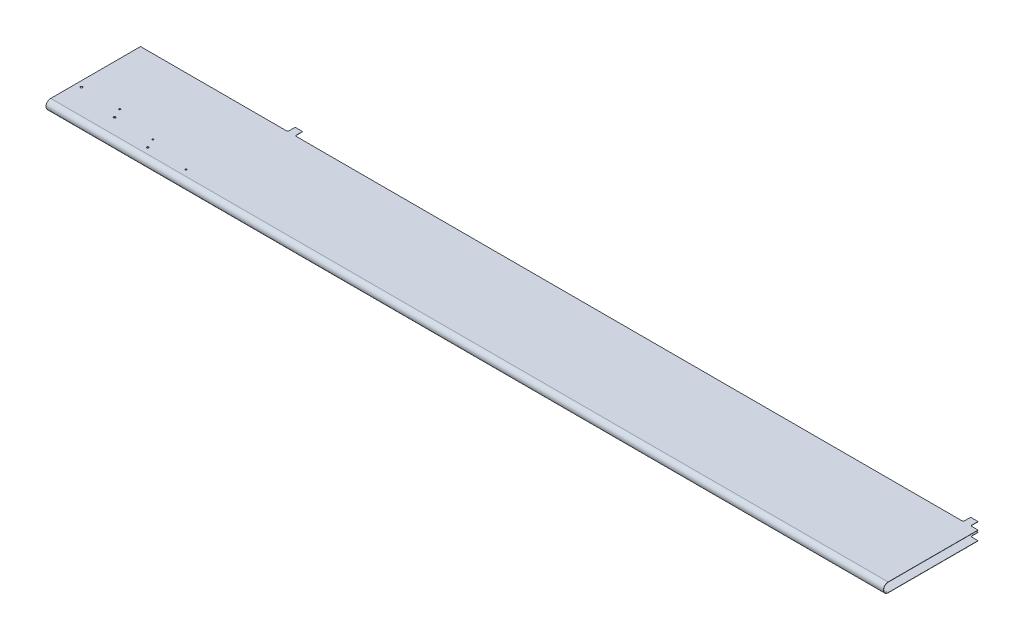
from build123d import *

# Parameters (mm, degrees)
BOSS_EXTRUDE1_DEPTH      = 5
BOSS_EXTRUDE1_DEPTH_BACK = 563.8
CUT_EXTRUDE1_DEPTH       = 7.42512
BOSS_EXTRUDE2_DEPTH      = 91.3
SKETCH4_R                = 0.69
SKETCH4_R_2              = 0.51
CUT_EXTRUDE2_DEPTH       = 2


with BuildPart() as part:
    # Sketch1 → Boss-Extrude1 (new body, two sides)
    with BuildSketch(Plane(origin=(0, 0, 0), x_dir=(0, 0, -1), z_dir=(1, 0, 0))) as boss_extrude1_sk:
        with BuildLine():
            Line((0, 0), (-61, 0))
            ThreePointArc((-61, 0), (-64.21256, -3.21256), (-61, -6.42512))
            Line((-61, -6.42512), (0, -6.42512))
            Line((0, -6.42512), (5, -6.42512))
            Line((5, -6.42512), (5, -6.26256))
            Line((5, -6.26256), (-61, -6.26256))
            ThreePointArc((-61, -6.26256), (-64.05, -3.21256), (-61, -0.16256))
            Line((-61, -0.16256), (5, -0.16256))
            Line((5, -0.16256), (5, 0))
            Line((5, 0), (0, 0))
        make_face()
    extrude(amount=BOSS_EXTRUDE1_DEPTH)
    extrude(boss_extrude1_sk.sketch, amount=-BOSS_EXTRUDE1_DEPTH_BACK)

    # Sketch2 → Cut-Extrude1 (cut, through all)
    with BuildSketch(Plane(origin=(0, 0, 0), x_dir=(1, 0, 0), z_dir=(0, 1, 0))):
        with BuildLine():
            Line((5, 0), (1, 0))
            ThreePointArc((1, 0), (0.292893219, 0.292893219), (0, 1))
            Line((0, 1), (0, 5))
            Line((0, 5), (-5, 5))
            Line((-5, 5), (-5, 1))
            ThreePointArc((-5, 1), (-5.292893219, 0.292893219), (-6, 0))
            Line((-6, 0), (-457.8, 0))
            ThreePointArc((-457.8, 0), (-458.507106781, 0.292893219), (-458.8, 1))
            Line((-458.8, 1), (-458.8, 5))
            Line((-458.8, 5), (-463.8, 5))
            Line((-463.8, 5), (-463.8, 1))
            ThreePointArc((-463.8, 1), (-464.092893219, 0.292893219), (-464.8, 0))
            Line((-464.8, 0), (-563.8, 0))
            Line((-563.8, 0), (-563.8, 10))
            Line((-563.8, 10), (5, 10))
            Line((5, 10), (5, 0))
        make_face()
    extrude(amount=-CUT_EXTRUDE1_DEPTH, mode=Mode.SUBTRACT)

    # Sketch3 → Boss-Extrude2 (add)
    with BuildSketch(Plane.ZY.offset(563.8)):
        with BuildLine():
            Line((61, -0.23114), (0, -0.23114))
            Line((0, -0.23114), (0, 0))
            Line((0, 0), (61, 0))
            ThreePointArc((61, 0), (64.21256, -3.21256), (61, -6.42512))
            Line((61, -6.42512), (0, -6.42512))
            Line((0, -6.42512), (0, -6.19398))
            Line((0, -6.19398), (61, -6.19398))
            ThreePointArc((61, -6.19398), (63.98142, -3.21256), (61, -0.23114))
        make_face()
    extrude(amount=-BOSS_EXTRUDE2_DEPTH)

    # Sketch4 → Cut-Extrude2 (cut)
    with BuildSketch(Plane(origin=(0, 0, 0), x_dir=(1, 0, 0), z_dir=(0, 1, 0))):
        with Locations(Location((-560.001, -43.918, 0), (0, 0, 270))):  # turned: the seam where the file's is
            Circle(SKETCH4_R)
        with Locations(Location((-534.001, -43.918, 0), (0, 0, 270))):  # turned: the seam where the file's is
            Circle(SKETCH4_R_2)
        with Locations(Location((-531.001, -50.418, 0), (0, 0, 270))):  # turned: the seam where the file's is
            Circle(SKETCH4_R)
        with Locations(Location((-505.001, -50.418, 0), (0, 0, 270))):  # turned: the seam where the file's is
            Circle(SKETCH4_R_2)
        with Locations(Location((-502.001, -56.918, 0), (0, 0, 270))):  # turned: the seam where the file's is
            Circle(SKETCH4_R)
        with Locations(Location((-476.001, -56.918, 0), (0, 0, 270))):  # turned: the seam where the file's is
            Circle(SKETCH4_R_2)
    extrude(amount=-CUT_EXTRUDE2_DEPTH, mode=Mode.SUBTRACT)


solid = part.part
